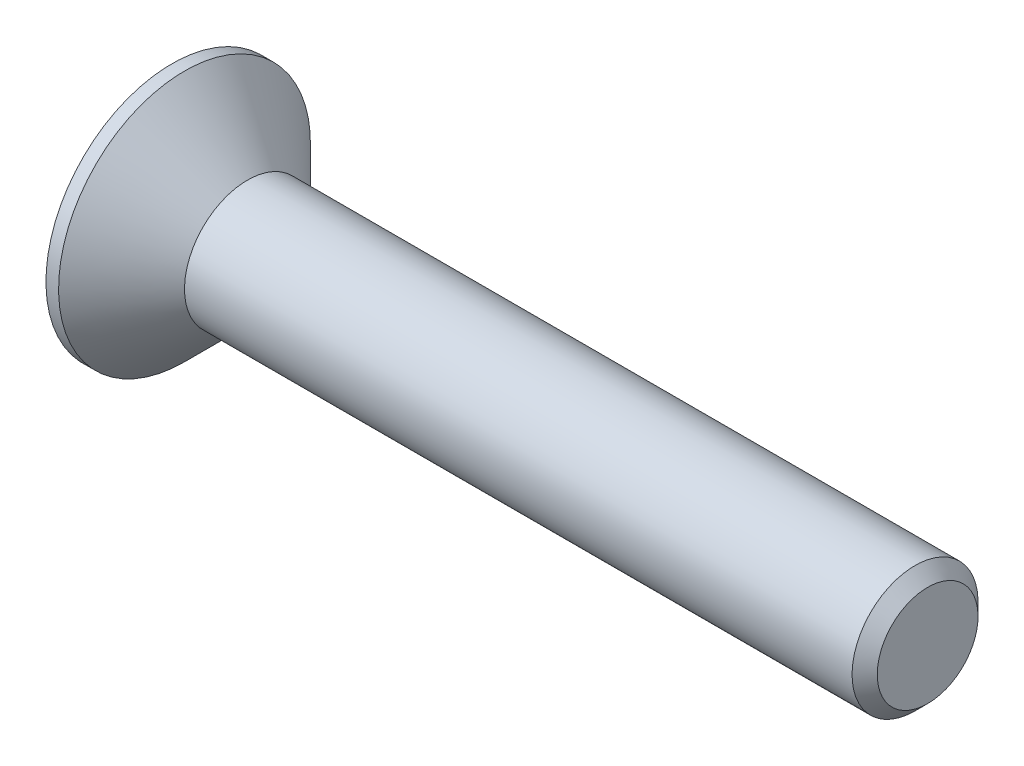
from build123d import *

# Parameters (mm, degrees)
CHAMFER1_SIZE      = 0.2
CUT_EXTRUDE1_DEPTH = 0.75


with BuildPart() as part:
    # Sketch1 → Revolve1 (revolve)
    with BuildSketch(Plane.XY):
        Polygon((0, 1), (-1, 2), (-1.2, 2), (-1.2, 0), (10.8, 0), (10.8, 1), align=None)
    revolve(axis=Axis((-1.2, 0, 0), (1, 0, 0)))

    # Chamfer1
    chamfer1_edges = [part.edges().sort_by_distance(p)[0] for p in [
        (10.8, -1, 0),
    ]]
    chamfer(chamfer1_edges, length=CHAMFER1_SIZE)

    # Sketch2 → Cut-Extrude1 (cut)
    with BuildSketch(Plane.ZY.offset(1.2)):
        Polygon((-0.75055535, 0), (-0.375277675, -0.65), (0.375277675, -0.65), (0.75055535, 0), (0.375277675, 0.65), (-0.375277675, 0.65), align=None)
    extrude(amount=-CUT_EXTRUDE1_DEPTH, mode=Mode.SUBTRACT)


solid = part.part
